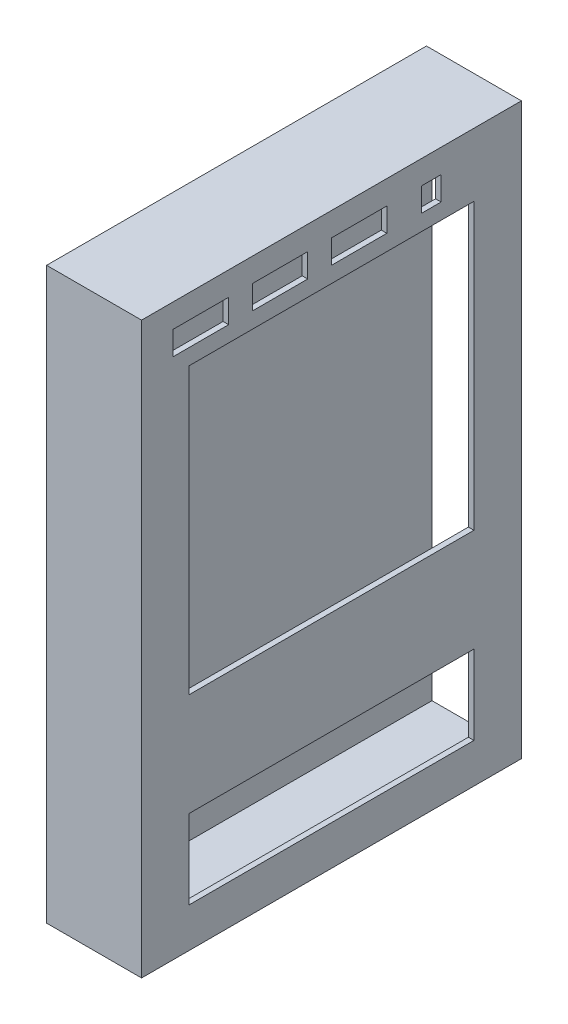
from build123d import *

# Parameters (mm, degrees)
SKETCH1_W            = 609.6
SKETCH1_H            = 914.4
OUTERBODIE_DEPTH     = 152.4
SHELL1_T             = -8.89
SKETCH3_W            = 457.2
SKETCH3_H            = 127
WIRE_DUCT_DEPTH      = 8.89
SKETCH2_W            = 457.2
SKETCH2_H            = 457.2
DISPLAY_CUTOUT_DEPTH = 8.89
SKETCH5_W            = 88.9
SKETCH5_H            = 38.1
SKETCH5_W_2          = 31.75
GAME_DISPLAY_DEPTH   = 8.89


with BuildPart() as part:
    # Sketch1 → OuterBodie (new body)
    with BuildSketch(Plane(origin=(0, 0, 0), x_dir=(0, 0, -1), z_dir=(1, 0, 0))):
        with Locations((0, 457.2)):
            Rectangle(SKETCH1_W, SKETCH1_H)
    extrude(amount=-OUTERBODIE_DEPTH)

    # Shell1
    shell1_openings = [part.faces().sort_by_distance(p)[0] for p in [
        (-76.2, 457.2, -304.8),
    ]]
    offset(amount=SHELL1_T, openings=shell1_openings, kind=Kind.INTERSECTION)

    # Sketch3 → Wire duct (cut)
    with BuildSketch(Plane(origin=(0, 0, 0), x_dir=(0, 0, -1), z_dir=(1, 0, 0))):
        with Locations((0, 127)):
            Rectangle(SKETCH3_W, SKETCH3_H)
    extrude(amount=-WIRE_DUCT_DEPTH, mode=Mode.SUBTRACT)

    # Sketch2 → Display cutout (cut)
    with BuildSketch(Plane(origin=(0, 0, 0), x_dir=(0, 0, -1), z_dir=(1, 0, 0))):
        with Locations((0, 584.2)):
            Rectangle(SKETCH2_W, SKETCH2_H)
    extrude(amount=-DISPLAY_CUTOUT_DEPTH, mode=Mode.SUBTRACT)

    # Sketch5 → Game Display (cut)
    with BuildSketch(Plane(origin=(0, 0, 0), x_dir=(0, 0, -1), z_dir=(1, 0, 0))):
        with Locations((-209.55, 857.25)):
            Rectangle(SKETCH5_W, SKETCH5_H)
        with Locations((-82.55, 857.25)):
            Rectangle(SKETCH5_W, SKETCH5_H)
        with Locations((44.45, 857.25)):
            Rectangle(SKETCH5_W, SKETCH5_H)
        with Locations((160.026262688, 857.25)):
            Rectangle(SKETCH5_W_2, SKETCH5_H)
    extrude(amount=-GAME_DISPLAY_DEPTH, mode=Mode.SUBTRACT)


solid = part.part
